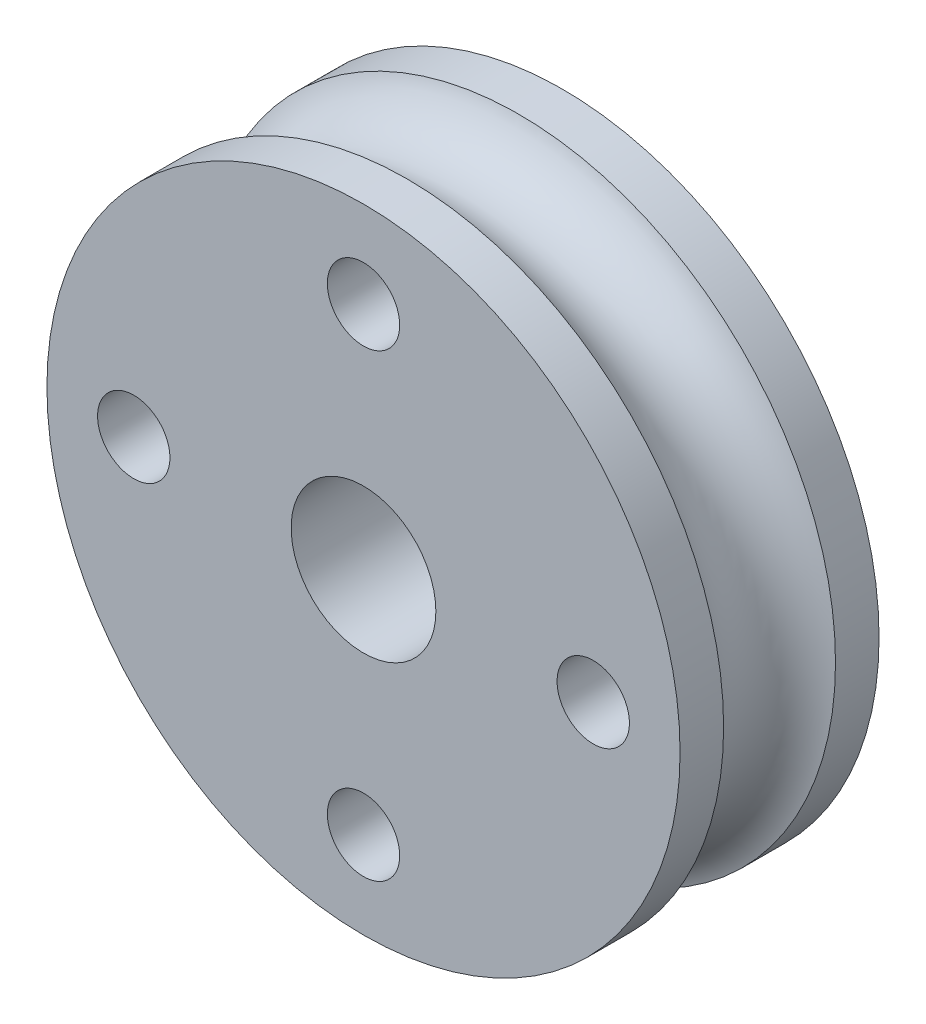
from build123d import *

# Parameters (mm, degrees)
SKETCH1_R             = 17.5
BOSS_EXTRUDE1_DEPTH   = 5.5
SKETCH2_R             = 3.25
F_8_0MM_DOWEL_HOLE1_D = 8
F_4_0MM_DOWEL_HOLE1_D = 4


with BuildPart() as part:
    # Sketch1 → Boss-Extrude1 (new body, symmetric)
    with BuildSketch(Plane.XY):
        Circle(SKETCH1_R)
    extrude(amount=BOSS_EXTRUDE1_DEPTH, both=True)

    # Sketch2 → Cut-Revolve1 (revolve, cut)
    with BuildSketch(Plane(origin=(0, 0, 0), x_dir=(0, 0, -1), z_dir=(1, 0, 0))):
        with Locations((0, 18.5)):
            Circle(SKETCH2_R)
    revolve(axis=Axis((0, 0, 0), (0, 0, -1)), mode=Mode.SUBTRACT)

    # Ø8.0mm Dowel Hole1 (through all)
    with Locations(Plane.XY.offset(5.5)):
        with Locations((0, 0)):
            Hole(F_8_0MM_DOWEL_HOLE1_D / 2)

    # Ø4.0mm Dowel Hole1 (through all)
    with Locations(Plane.XY.offset(5.5)):
        with Locations((0, 12.7), (12.7, 0), (0, -12.7), (-12.7, 0)):
            Hole(F_4_0MM_DOWEL_HOLE1_D / 2)


solid = part.part
